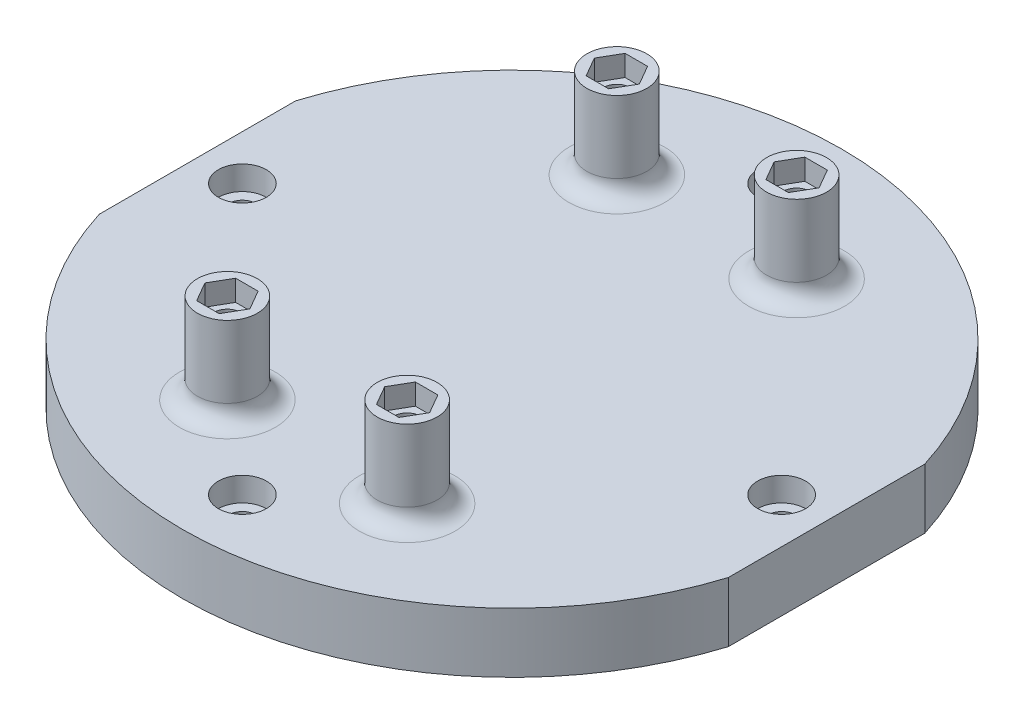
from build123d import *

# Parameters (mm, degrees)
BOSS_EXTRUDE1_DEPTH            = 10
CBORE_FOR_M4_SHCS1_D           = 4.5
CBORE_FOR_M4_SHCS1_CBORE_D     = 8
CBORE_FOR_M4_SHCS1_CBORE_DEPTH = 4
CBORE_FOR_M4_SHCS2_D           = 4.5
CBORE_FOR_M4_SHCS2_CBORE_D     = 8
CBORE_FOR_M4_SHCS2_CBORE_DEPTH = 4
SKETCH8_R                      = 5
BOSS_EXTRUDE2_DEPTH            = 15
FILLET1_R                      = 3
SKETCH10_R                     = 2.25
BOSS_EXTRUDE3_DEPTH            = 11.5


with BuildPart() as part:
    # Sketch1 → Boss-Extrude1 (new body)
    with BuildSketch(Plane(origin=(0, 0, 0), x_dir=(1, 0, 0), z_dir=(0, 1, 0))):
        with BuildLine():
            Line((-52.5, -16.393596311), (-52.5, 16.393596311))
            ThreePointArc((-52.5, 16.393596311), (0, 55), (52.5, 16.393596311))
            Line((52.5, 16.393596311), (52.5, -16.393596311))
            ThreePointArc((52.5, -16.393596311), (0, -55), (-52.5, -16.393596311))
        make_face()
    extrude(amount=BOSS_EXTRUDE1_DEPTH)

    # CBORE for M4 SHCS1 (through all)
    with Locations(Plane(origin=(0, 10, 0), x_dir=(1, 0, 0), z_dir=(0, 1, 0))):
        with Locations((-45, 0), (0, 45), (45, 0), (0, -45)):
            CounterBoreHole(CBORE_FOR_M4_SHCS1_D / 2, CBORE_FOR_M4_SHCS1_CBORE_D / 2, CBORE_FOR_M4_SHCS1_CBORE_DEPTH)

    # CBORE for M4 SHCS2 (through all)
    with Locations(Plane(origin=(0, 0, 0), x_dir=(-1, 0, 0), z_dir=(0, -1, 0))):
        with Locations((15, -32.5), (-15, -32.5), (15, 32.5), (-15, 32.5)):
            CounterBoreHole(CBORE_FOR_M4_SHCS2_D / 2, CBORE_FOR_M4_SHCS2_CBORE_D / 2, CBORE_FOR_M4_SHCS2_CBORE_DEPTH)

    # Sketch8 → Boss-Extrude2 (add)
    with BuildSketch(Plane(origin=(0, 10, 0), x_dir=(1, 0, 0), z_dir=(0, 1, 0))):
        with Locations((-15, 32.5)):
            Circle(SKETCH8_R)
        Polygon((-11.24722325, 32.5), (-13.123611625, 35.75), (-16.876388375, 35.75), (-18.75277675, 32.5), (-16.876388375, 29.25), (-13.123611625, 29.25), align=None, mode=Mode.SUBTRACT)
        with Locations((15, 32.5)):
            Circle(SKETCH8_R)
        Polygon((13.123611625, 29.25), (11.24722325, 32.5), (13.123611625, 35.75), (16.876388375, 35.75), (18.75277675, 32.5), (16.876388375, 29.25), align=None, mode=Mode.SUBTRACT)
        with Locations((-15, -32.5)):
            Circle(SKETCH8_R)
        Polygon((-13.123611625, -29.25), (-11.24722325, -32.5), (-13.123611625, -35.75), (-16.876388375, -35.75), (-18.75277675, -32.5), (-16.876388375, -29.25), align=None, mode=Mode.SUBTRACT)
        with Locations((15, -32.5)):
            Circle(SKETCH8_R)
        Polygon((16.876388375, -29.25), (13.123611625, -29.25), (11.24722325, -32.5), (13.123611625, -35.75), (16.876388375, -35.75), (18.75277675, -32.5), align=None, mode=Mode.SUBTRACT)
    extrude(amount=BOSS_EXTRUDE2_DEPTH)

    # Fillet1
    fillet1_edges = [part.edges().sort_by_distance(p)[0] for p in [
        (-20, 10, 32.5),
        (10, 10, 32.5),
        (-20, 10, -32.5),
        (10, 10, -32.5),
    ]]
    fillet(fillet1_edges, radius=FILLET1_R)

    # Sketch10 → Boss-Extrude3 (add)
    with BuildSketch(Plane(origin=(0, 10, 0), x_dir=(1, 0, 0), z_dir=(0, 1, 0))):
        Polygon((-13.123611625, 35.75), (-16.876388375, 35.75), (-18.75277675, 32.5), (-16.876388375, 29.25), (-13.123611625, 29.25), (-11.24722325, 32.5), align=None)
        with Locations((-15, 32.5)):
            Circle(SKETCH10_R, mode=Mode.SUBTRACT)
        Polygon((11.24722325, 32.5), (13.123611625, 35.75), (16.876388375, 35.75), (18.75277675, 32.5), (16.876388375, 29.25), (13.123611625, 29.25), align=None)
        with Locations((15, 32.5)):
            Circle(SKETCH10_R, mode=Mode.SUBTRACT)
        Polygon((13.123611625, -29.25), (11.24722325, -32.5), (13.123611625, -35.75), (16.876388375, -35.75), (18.75277675, -32.5), (16.876388375, -29.25), align=None)
        with Locations((15, -32.5)):
            Circle(SKETCH10_R, mode=Mode.SUBTRACT)
        Polygon((-11.24722325, -32.5), (-13.123611625, -35.75), (-16.876388375, -35.75), (-18.75277675, -32.5), (-16.876388375, -29.25), (-13.123611625, -29.25), align=None)
        with Locations((-15, -32.5)):
            Circle(SKETCH10_R, mode=Mode.SUBTRACT)
    extrude(amount=BOSS_EXTRUDE3_DEPTH)


solid = part.part
